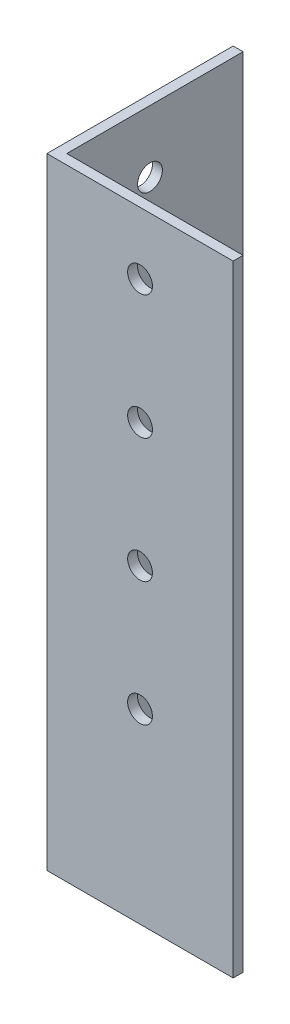
from build123d import *

# Parameters (mm, degrees)
EXTRUDE_1_DEPTH     = 250
SKETCH_2_R          = 5
CUT_EXTRUDE_1_DEPTH = 10
SKETCH_3_R          = 5
CUT_EXTRUDE_2_DEPTH = 10


with BuildPart() as part:
    # Эскиз1 → Вытянуть-Тонкостенный1 (new body)
    with BuildSketch(Plane(origin=(0, 0, 0), x_dir=(1, 0, 0), z_dir=(0, 1, 0))):
        Polygon((0, 75), (0, 0), (75, 0), (75, 4), (4, 4), (4, 75), align=None)
    extrude(amount=EXTRUDE_1_DEPTH)

    # Эскиз2 → Вырез-Вытянуть1 (cut)
    with BuildSketch(Plane.XY):
        with Locations((37.5, 225)):
            Circle(SKETCH_2_R)
        with Locations((37.5, 175)):
            Circle(SKETCH_2_R)
        with Locations((37.5, 125)):
            Circle(SKETCH_2_R)
        with Locations((37.5, 75)):
            Circle(SKETCH_2_R)
    extrude(amount=-CUT_EXTRUDE_1_DEPTH, mode=Mode.SUBTRACT)

    # Эскиз3 → Вырез-Вытянуть2 (cut)
    with BuildSketch(Plane.ZY):
        with Locations((-37.5, 225)):
            Circle(SKETCH_3_R)
        with Locations((-37.5, 175)):
            Circle(SKETCH_3_R)
        with Locations((-37.5, 125)):
            Circle(SKETCH_3_R)
        with Locations((-37.5, 75)):
            Circle(SKETCH_3_R)
    extrude(amount=-CUT_EXTRUDE_2_DEPTH, mode=Mode.SUBTRACT)


solid = part.part
